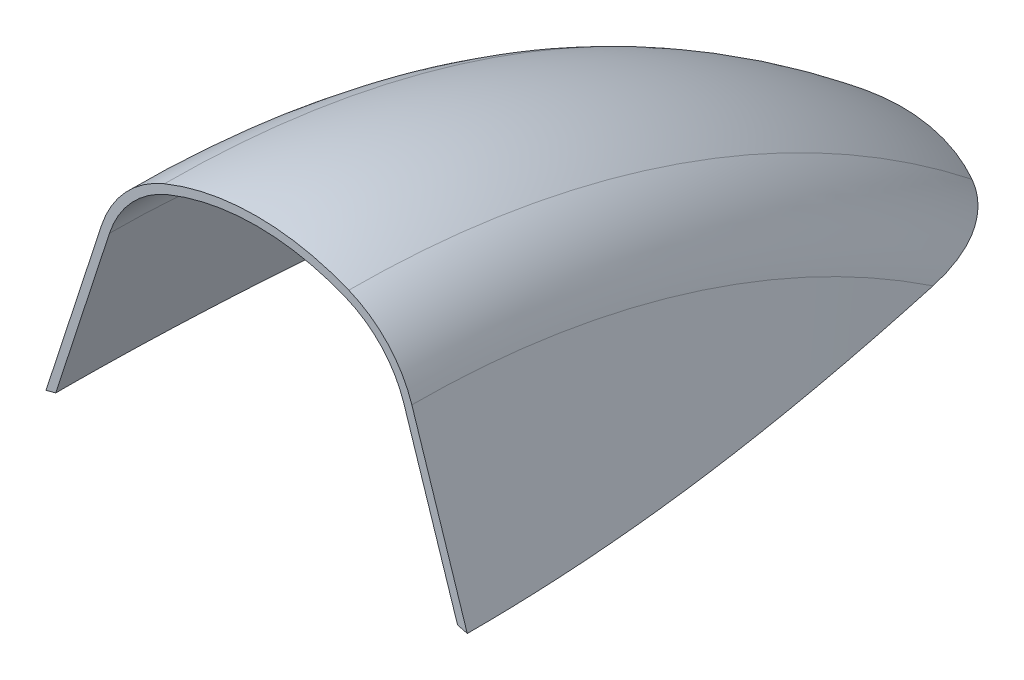
from build123d import *

# Parameters (mm, degrees)
REVOLVE1_ANGLE     = 56
SKETCH2_R          = 152.4
CUT_EXTRUDE1_DEPTH = 309.88


with BuildPart() as part:
    # Sketch1 → Revolve1 (revolve)
    with BuildSketch(Plane.XY):
        with BuildLine():
            Line((29.137194784, 179.160976849), (39.542245278, 147.180742077))
            ThreePointArc((39.542245278, 147.180742077), (38.630482432, 147.422677452), (37.717239544, 147.658964649))
            Line((37.717239544, 147.658964649), (27.627587493, 178.669812847))
            ThreePointArc((27.627587493, 178.669812847), (23.462294361, 185.748899875), (16.703713988, 190.41631151))
            ThreePointArc((16.703713988, 190.41631151), (0, 193.690277018), (-16.703713988, 190.41631151))
            ThreePointArc((-16.703713988, 190.41631151), (-23.462294361, 185.748899875), (-27.627587493, 178.669812847))
            Line((-27.627587493, 178.669812847), (-37.717239544, 147.658964649))
            ThreePointArc((-37.717239544, 147.658964649), (-38.630482432, 147.422677452), (-39.542245278, 147.180742077))
            Line((-39.542245278, 147.180742077), (-29.137194784, 179.160976849))
            ThreePointArc((-29.137194784, 179.160976849), (-24.624793891, 186.829987796), (-17.302998471, 191.886350359))
            ThreePointArc((-17.302998471, 191.886350359), (0, 195.277776974), (17.302998471, 191.886350359))
            ThreePointArc((17.302998471, 191.886350359), (24.624793891, 186.829987796), (29.137194784, 179.160976849))
        make_face()
    revolve(axis=Axis((0, 2.54, 0), (-1, 0, 0)), revolution_arc=REVOLVE1_ANGLE)

    # Sketch2 → Cut-Extrude1 (cut)
    with BuildSketch(Plane.XY):
        Circle(SKETCH2_R)
    extrude(amount=-CUT_EXTRUDE1_DEPTH, mode=Mode.SUBTRACT)


solid = part.part
